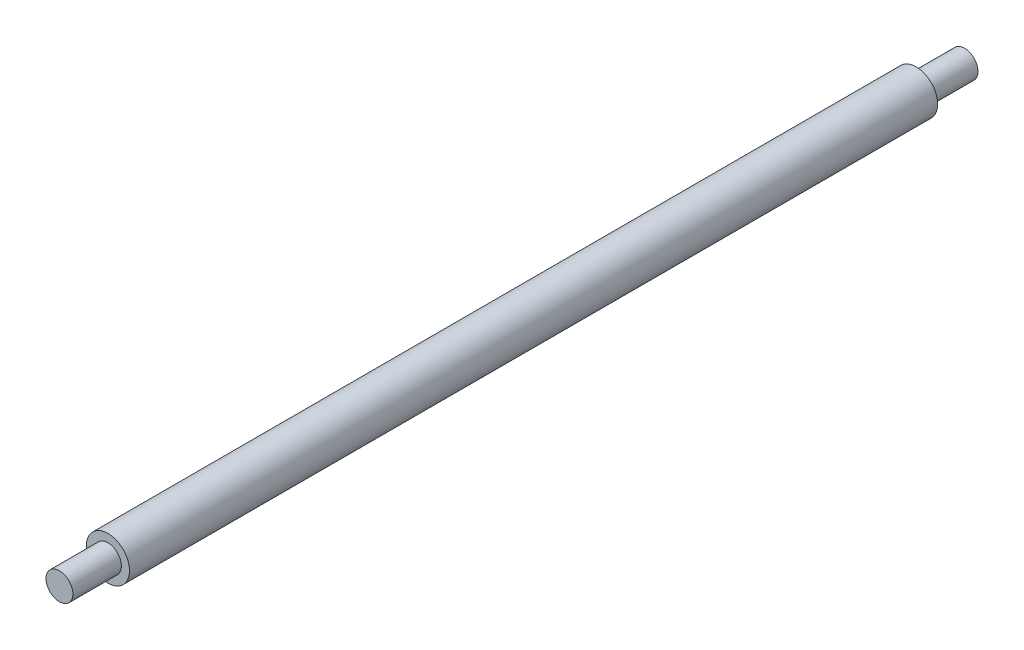
from build123d import *

# Parameters (mm, degrees)
SKETCH1_R           = 20
BOSS_EXTRUDE1_DEPTH = 750
SKETCH2_R           = 12.5
BOSS_EXTRUDE2_DEPTH = 45
SKETCH3_R           = 12.5
BOSS_EXTRUDE3_DEPTH = 45


with BuildPart() as part:
    # Sketch1 → Boss-Extrude1 (new body)
    with BuildSketch(Plane.XY):
        Circle(SKETCH1_R)
    extrude(amount=BOSS_EXTRUDE1_DEPTH)

    # Sketch2 → Boss-Extrude2 (add)
    with BuildSketch(Plane.XY.offset(750)):
        Circle(SKETCH2_R)
    extrude(amount=BOSS_EXTRUDE2_DEPTH)

    # Sketch3 → Boss-Extrude3 (add)
    with BuildSketch(Plane(origin=(0, 0, 0), x_dir=(-1, 0, 0), z_dir=(0, 0, -1))):
        Circle(SKETCH3_R)
    extrude(amount=BOSS_EXTRUDE3_DEPTH)


solid = part.part
